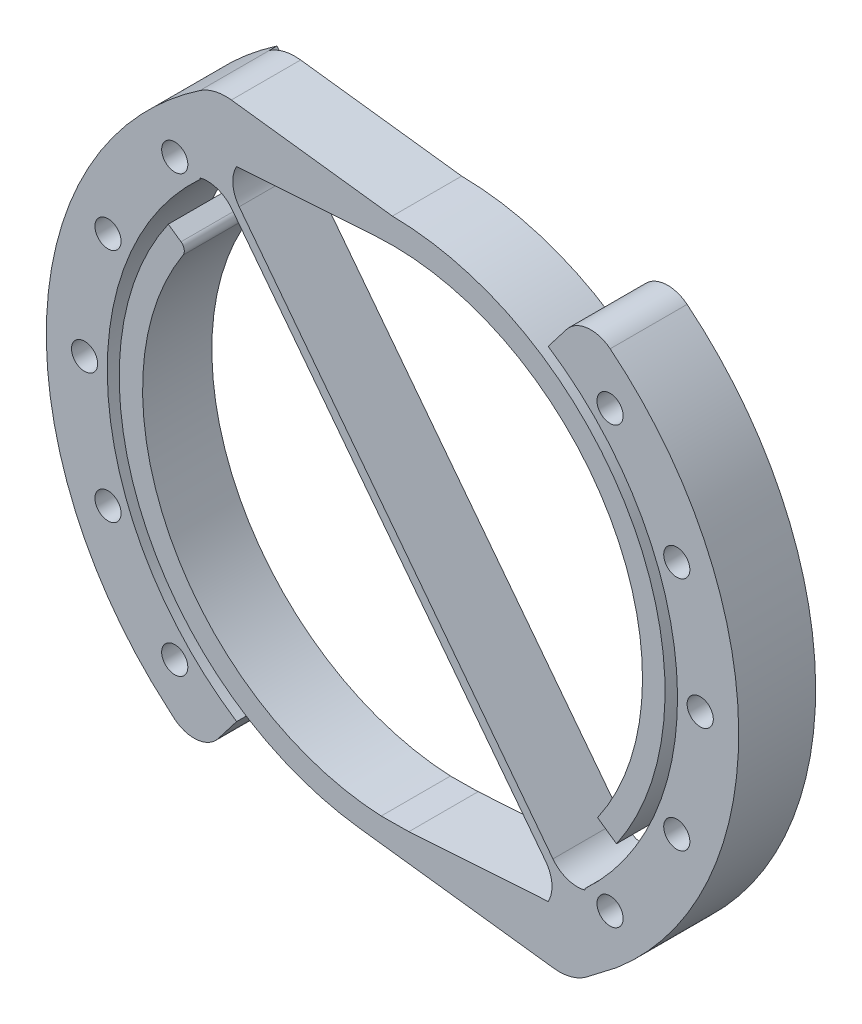
from build123d import *

# Parameters (mm, degrees)
BOSS_EXTRUDE1_DEPTH     = 2.25
BOSS_EXTRUDE2_DEPTH     = 0.5
SKETCH5_R               = 0.850002184
CUT_EXTRUDE1_DEPTH      = 1
CUT_EXTRUDE1_DEPTH_BACK = 6


with BuildPart() as part:
    # Sketch2 → Boss-Extrude1 (new body, symmetric)
    with BuildSketch(Plane.XY):
        with BuildLine():
            Line((2.713147674, 1.38944985), (1.528065997, -0.150989389))
            ThreePointArc((1.528065997, -0.150989389), (0.17725111, -0.917704623), (-1.31492025, -0.486453258))
            Line((-1.31492025, -0.486453258), (-1.753865618, -0.096037363))
            ThreePointArc((-1.753865618, -0.096037363), (-9.620538113, 15.815478855), (-3.478285545, 32.468815395))
            ThreePointArc((-3.478285545, 32.468815395), (-1.657553469, 34.19316142), (0.335322036, 35.715292075))
            ThreePointArc((0.335322036, 35.715292075), (1.310576189, 36.140071747), (2.372755236, 36.197813468))
            Line((2.372755236, 36.197813468), (12.835373957, 34.894529227))
            ThreePointArc((12.835373957, 34.894529227), (28.536577221, 25.247997312), (27.396378685, 6.85551762))
            Line((27.396378685, 6.85551762), (26.165923945, 7.71335154))
            ThreePointArc((26.165923945, 7.71335154), (26.986392928, 24.995972492), (11.764919509, 33.222083557))
            Line((11.764919509, 33.222083557), (2.713147674, 32.624522546))
            ThreePointArc((2.713147674, 32.624522546), (2.470709746, 31.507408509), (2.879736705, 30.439973796))
            Line((2.879736705, 30.439973796), (23.266595715, 3.939876853))
            ThreePointArc((23.266595715, 3.939876853), (24.193426287, 3.270845706), (25.335310798, 3.218717494))
            Line((25.335310798, 3.218717494), (25.335310798, 3.30054722))
            ThreePointArc((25.335310798, 3.30054722), (31.300372108, 18.542612289), (22.957572367, 32.624522546))
            Line((22.957572367, 32.624522546), (24.142654044, 34.164961785))
            ThreePointArc((24.142654044, 34.164961785), (25.492802118, 34.931598224), (26.984595921, 34.501269859))
            ThreePointArc((26.984595921, 34.501269859), (35.334137123, 17.306419127), (27.42640432, -0.096037363))
            Line((27.42640432, -0.096037363), (25.335310798, -1.701329119))
            ThreePointArc((25.335310798, -1.701329119), (24.360060505, -2.126090593), (23.297891975, -2.183826688))
            Line((23.297891975, -2.183826688), (10.641243869, -0.60724147))
            ThreePointArc((10.641243869, -0.60724147), (-3.379346512, 9.784930922), (-1.725632249, 27.158457646))
            Line((-1.725632249, 27.158457646), (-0.899188364, 26.582287247))
            ThreePointArc((-0.899188364, 26.582287247), (-0.694395528, 26.267887803), (-0.765964702, 25.899560545))
            ThreePointArc((-0.765964702, 25.899560545), (-1.606558349, 9.608289856), (12.106530022, 0.772945738))
            Line((12.106530022, 0.772945738), (13.905800532, 0.791888839))
            Line((13.905800532, 0.791888839), (22.957572367, 1.38944985))
            ThreePointArc((22.957572367, 1.38944985), (23.200013724, 2.506566373), (22.790986515, 3.574004371))
            Line((22.790986515, 3.574004371), (2.404127505, 30.074101314))
            ThreePointArc((2.404127505, 30.074101314), (1.477253865, 30.743151427), (0.335322036, 30.795252278))
            Line((0.335322036, 30.795252278), (0.335322036, 30.713422552))
            ThreePointArc((0.335322036, 30.713422552), (-5.629385297, 15.471362635), (2.713147674, 1.38944985))
        make_face()
    extrude(amount=BOSS_EXTRUDE1_DEPTH, both=True)

    # Sketch3 → Boss-Extrude2 (add)
    with BuildSketch(Plane(origin=(0, 0, -2.25), x_dir=(-1, 0, 0), z_dir=(0, 0, -1))):
        with BuildLine():
            Line((-25.335310798, 3.218717494), (-22.957572367, 1.38944985))
            Line((-22.957572367, 1.38944985), (-25.335310798, -1.701329119))
            Line((-25.335310798, -1.701329119), (-27.42640432, -0.096037363))
            ThreePointArc((-27.42640432, -0.096037363), (-35.334137123, 17.306419127), (-26.984595921, 34.501269859))
            ThreePointArc((-26.984595921, 34.501269859), (-25.492802118, 34.931598224), (-24.142654044, 34.164961785))
            Line((-24.142654044, 34.164961785), (-22.957572367, 32.624522546))
            ThreePointArc((-22.957572367, 32.624522546), (-31.300372108, 18.542612289), (-25.335310798, 3.30054722))
            Line((-25.335310798, 3.30054722), (-25.335310798, 3.218717494))
        make_face()
        with BuildLine():
            Line((-0.335322036, 30.795252278), (-2.713147674, 32.624522546))
            Line((-2.713147674, 32.624522546), (-0.335322036, 35.715292075))
            ThreePointArc((-0.335322036, 35.715292075), (1.657553469, 34.19316142), (3.478285545, 32.468815395))
            ThreePointArc((3.478285545, 32.468815395), (9.620538113, 15.815478855), (1.753865618, -0.096037363))
            Line((1.753865618, -0.096037363), (1.31492025, -0.486453258))
            ThreePointArc((1.31492025, -0.486453258), (-0.17725111, -0.917704623), (-1.528065997, -0.150989389))
            Line((-1.528065997, -0.150989389), (-2.713147674, 1.38944985))
            ThreePointArc((-2.713147674, 1.38944985), (5.629385297, 15.471362635), (-0.335322036, 30.713422552))
            Line((-0.335322036, 30.713422552), (-0.335322036, 30.795252278))
        make_face()
    extrude(amount=BOSS_EXTRUDE2_DEPTH)

    # Sketch5 → Cut-Extrude1 (cut, two sides)
    with BuildSketch(Plane(origin=(0, 0, -2.75), x_dir=(-1, 0, 0), z_dir=(0, 0, -1))) as cut_extrude1_sk:
        with Locations((-31.312900109, 24.660626427)):
            Circle(SKETCH5_R)
        with Locations((-32.835321764, 17.006965176)):
            Circle(SKETCH5_R)
        with Locations((-31.312900109, 9.353290058)):
            Circle(SKETCH5_R)
        with Locations((-26.977454917, 2.864826813)):
            Circle(SKETCH5_R)
        with Locations((1.306812691, 2.864826813)):
            Circle(SKETCH5_R)
        with Locations((5.642277886, 24.660626427)):
            Circle(SKETCH5_R)
        with Locations((1.306812691, 31.14910354)):
            Circle(SKETCH5_R)
        with Locations((-26.977454917, 31.14910354)):
            Circle(SKETCH5_R)
        with Locations((5.642277886, 9.353290058)):
            Circle(SKETCH5_R)
        with Locations((7.164679538, 17.006965176)):
            Circle(SKETCH5_R)
    extrude(amount=CUT_EXTRUDE1_DEPTH, mode=Mode.SUBTRACT)
    extrude(cut_extrude1_sk.sketch, amount=-CUT_EXTRUDE1_DEPTH_BACK, mode=Mode.SUBTRACT)


solid = part.part
